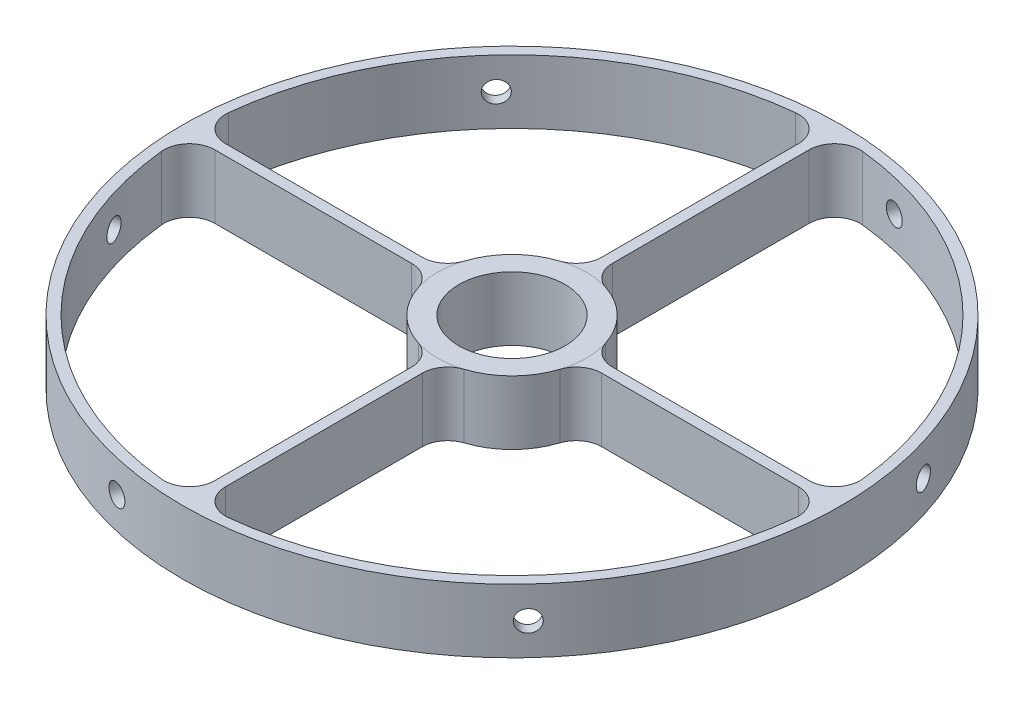
from build123d import *

# Parameters (mm, degrees)
CENTER_RING_R      = 22.225
CENTER_RING_R_2    = 15.875
CENTER_DEPTH       = 9.525
OUTER_R            = 98.425
OUTER_R_2          = 95.25
OUTER_RING_DEPTH   = 9.525
BEAM_START         = -25.456769
BEEAM_W            = 3.175
BEEAM_H            = 19.05
BEAM_DEPTH         = 73.081769
CIRPATTERN1_COUNT  = 4
FILLET1_R          = 7.62
CUT_EXTRUDE2_START = -3.227931
SKETCH13_R         = 3.175
CUT_EXTRUDE2_DEPTH = 3.227931
CIRPATTERN3_COUNT  = 6


with BuildPart() as part:
    # Center Ring → Center (new body, symmetric)
    with BuildSketch(Plane(origin=(0, 0, 0), x_dir=(1, 0, 0), z_dir=(0, 1, 0))):
        Circle(CENTER_RING_R)
        Circle(CENTER_RING_R_2, mode=Mode.SUBTRACT)
    extrude(amount=CENTER_DEPTH, both=True)



with BuildPart() as body_2:
    # Outer → Outer Ring (new body, symmetric)
    with BuildSketch(Plane(origin=(0, 0, 0), x_dir=(1, 0, 0), z_dir=(0, 1, 0))):
        Circle(OUTER_R)
        Circle(OUTER_R_2, mode=Mode.SUBTRACT)
    extrude(amount=OUTER_RING_DEPTH, both=True)


with BuildPart() as part_1:
    add(part.part)

    add(body_2.part)  # Beam merges body 2
    # beeam → Beam (add)
    with BuildSketch(Plane.XY.offset(47.625).offset(BEAM_START)):
        Rectangle(BEEAM_W, BEEAM_H)
    beam = extrude(amount=BEAM_DEPTH)

    # CirPattern1: Beam ×4 about axis
    cirpattern1_axis = Axis((0, 0, 0), (0, 1, 0))
    for i in range(1, CIRPATTERN1_COUNT):
        add(beam.rotate(cirpattern1_axis, i * 360 / CIRPATTERN1_COUNT))

    # Fillet1
    fillet1_edges = [part_1.edges().sort_by_distance(p)[0] for p in [
        (-1.5875, 0, 22.168231),
        (-1.5875, 0, 95.236769915),
        (1.5875, 0, 22.168231),
        (1.5875, 0, 95.236769915),
        (-22.168231, 0, 1.5875),
        (-95.236769915, 0, 1.5875),
        (-22.168231, 0, -1.5875),
        (-95.236769915, 0, -1.5875),
        (1.5875, 0, -22.168231),
        (1.5875, 0, -95.236769915),
        (-1.5875, 0, -22.168231),
        (-1.5875, 0, -95.236769915),
        (22.168231, 0, 1.5875),
        (95.236769915, 0, 1.5875),
        (22.168231, 0, -1.5875),
        (95.236769915, 0, -1.5875),
    ]]
    fillet(fillet1_edges, radius=FILLET1_R)

    # Sketch13 → Cut-Extrude2 (cut)
    with BuildSketch(Plane(origin=(71.983488082, 0, 67.125688589), x_dir=(0, -1, 0), z_dir=(0.731353702, 0, 0.68199836)).offset(CUT_EXTRUDE2_START)):
        Circle(SKETCH13_R)
    cut_extrude2 = extrude(amount=CUT_EXTRUDE2_DEPTH, mode=Mode.SUBTRACT)

    # CirPattern3: Cut-Extrude2 ×6 about axis
    cirpattern3_axis = Axis((0, 9.525, 0), (0, -1, 0))
    for i in range(1, CIRPATTERN3_COUNT):
        add(cut_extrude2.rotate(cirpattern3_axis, i * 360 / CIRPATTERN3_COUNT), mode=Mode.SUBTRACT)


solid = part_1.part
